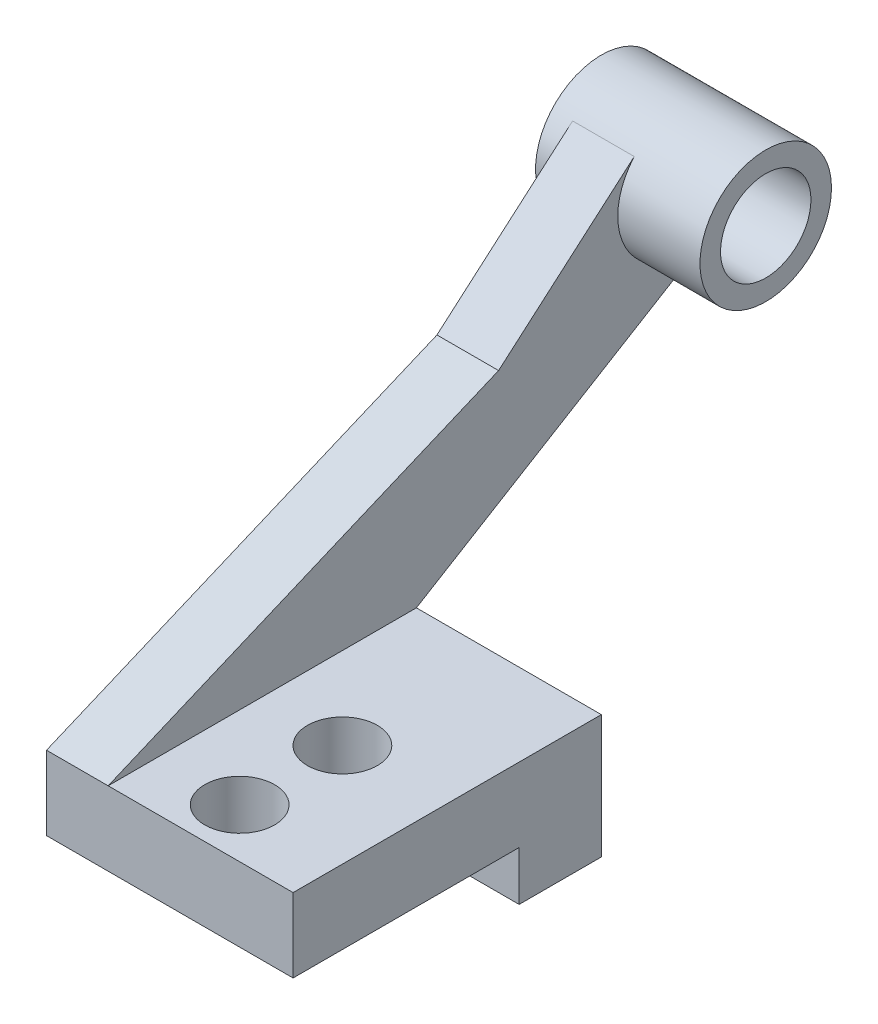
from build123d import *

# Parameters (mm, degrees)
BOSS_EXTRUDE1_DEPTH      = 60
SKETCH2_R                = 8.5
CUT_EXTRUDE1_DEPTH       = 60
BOSS_EXTRUDE2_DEPTH      = 15
SKETCH3_R                = 16
SKETCH3_R_2              = 11
BOSS_EXTRUDE3_DEPTH      = 20
BOSS_EXTRUDE3_DEPTH_BACK = 20
CUT_EXTRUDE2_DEPTH       = 57


with BuildPart() as part:
    # Sketch1 → Boss-Extrude1 (new body)
    with BuildSketch(Plane(origin=(0, 0, 0), x_dir=(0, 0, -1), z_dir=(1, 0, 0))):
        Polygon((-31.570634591, -10.443354749), (-31.570634591, -28.443354749), (23.429365409, -28.443354749), (23.429365409, -40.443354749), (43.429365409, -40.443354749), (43.429365409, -10.443354749), align=None)
    extrude(amount=BOSS_EXTRUDE1_DEPTH)

    # Sketch2 → Cut-Extrude1 (cut)
    with BuildSketch(Plane(origin=(0, -10.443354749, 0), x_dir=(1, 0, 0), z_dir=(0, 1, 0))):
        with Locations(Location((35, -19.570634591, 0), (0, 0, 270))):
            Circle(SKETCH2_R)
        with Locations(Location((35, 5.429365409, 0), (0, 0, 270))):
            Circle(SKETCH2_R)
    extrude(amount=-CUT_EXTRUDE1_DEPTH, mode=Mode.SUBTRACT)

    # 3DSketch1 → Boss-Extrude2 (add)
    with BuildSketch(Plane(origin=(0, -10.443354749, 31.570634591), x_dir=(0, 0.28727544621498696, -0.9578480140408394), z_dir=(1, 0, 0))):
        Polygon((0, 0), (71.838601053, -21.545658466), (155.320085422, 0), (146.20131027, 30.673244689), (102.486579182, 11.022753171), align=None)
    extrude(amount=BOSS_EXTRUDE2_DEPTH)

    # Sketch3 → Boss-Extrude3 (add, two sides)
    with BuildSketch(Plane(origin=(15, 0, 0), x_dir=(0, 0, -1), z_dir=(1, 0, 0))) as boss_extrude3_sk:
        with Locations((108.429365409, 47.556645251)):
            Circle(SKETCH3_R)
        with Locations((108.429365409, 47.556645251)):
            Circle(SKETCH3_R_2, mode=Mode.SUBTRACT)
    extrude(amount=BOSS_EXTRUDE3_DEPTH)
    extrude(boss_extrude3_sk.sketch, amount=-BOSS_EXTRUDE3_DEPTH_BACK)

    # Sketch4 → Cut-Extrude2 (cut)
    with BuildSketch(Plane(origin=(15, 0, 0), x_dir=(0, 0, -1), z_dir=(1, 0, 0))):
        with BuildLine():
            Line((114.460827221, 38.357652457), (102.397903597, 56.755638044))
            ThreePointArc((102.397903597, 56.755638044), (99.230372615, 41.525183439), (114.460827221, 38.357652457))
        make_face()
    extrude(amount=-CUT_EXTRUDE2_DEPTH, mode=Mode.SUBTRACT)


solid = part.part
